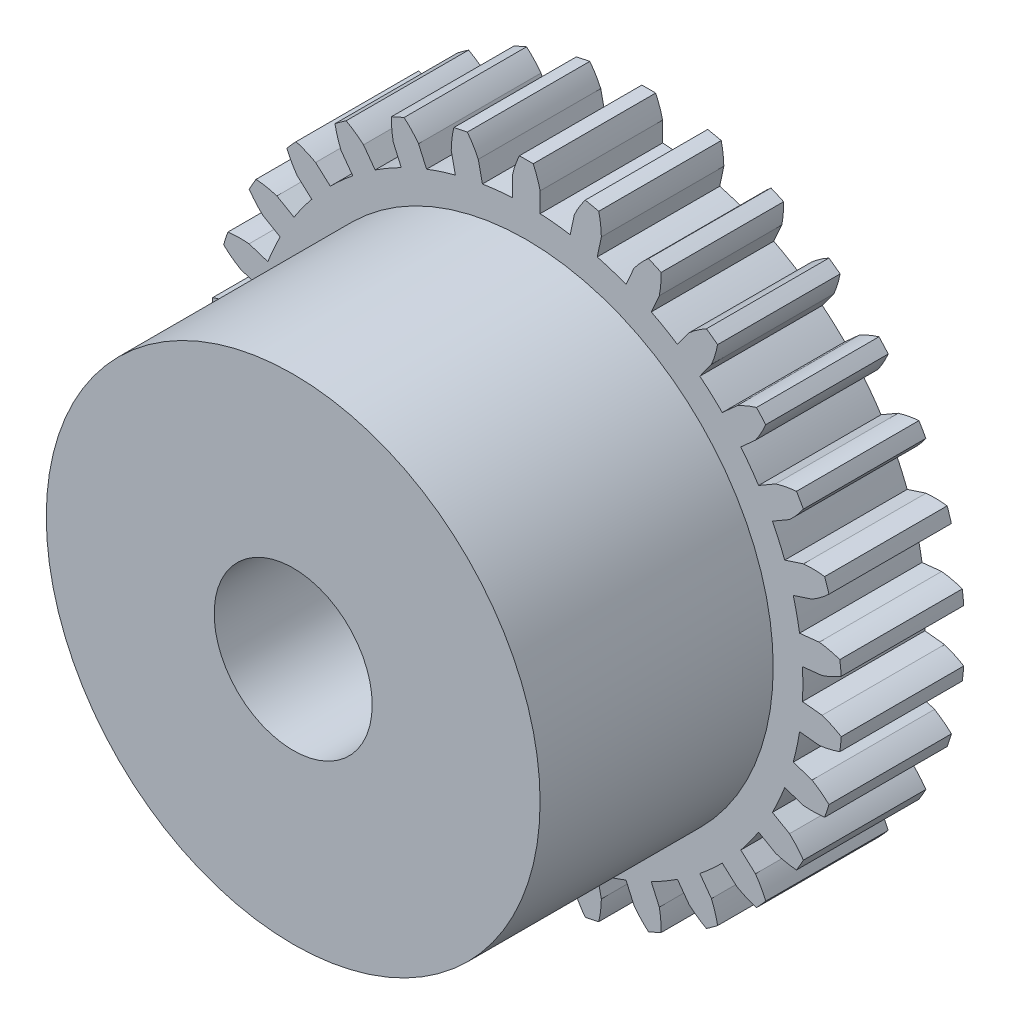
from build123d import *

# Parameters (mm, degrees)
BOSS_EXTRUDE1_DEPTH = 6.2
SKETCH2_R           = 12.5
BOSS_EXTRUDE2_DEPTH = 11.8
CUT_EXTRUDE1_REACH  = 20
SKETCH3_R           = 4
CUT_EXTRUDE2_REACH  = 18
SKETCH4_R           = 1.25


with BuildPart() as part:
    # Sketch1 → Boss-Extrude1 (new body)
    with BuildSketch(Plane.XY):
        with BuildLine():
            ThreePointArc((2.983439386, 15.719385784), (2.681848363, 15.275077472), (2.43033131, 14.8006239))
            Line((2.43033131, 14.8006239), (2.222419619, 13.822476299))
            ThreePointArc((2.222419619, 13.822476299), (1.463398486, 13.923306535), (0.7, 13.982489049))
            Line((0.7, 13.982489049), (0.7, 14.982489049))
            ThreePointArc((0.7, 14.982489049), (0.552623642, 15.498868008), (0.35, 15.996171417))
            ThreePointArc((0.35, 15.996171417), (0, 16), (-0.35, 15.996171417))
            ThreePointArc((-0.35, 15.996171417), (-0.552623642, 15.498868008), (-0.7, 14.982489049))
            Line((-0.7, 14.982489049), (-0.7, 13.982489049))
            ThreePointArc((-0.7, 13.982489049), (-1.463398486, 13.923306535), (-2.222419619, 13.822476299))
            Line((-2.222419619, 13.822476299), (-2.43033131, 14.8006239))
            ThreePointArc((-2.43033131, 14.8006239), (-2.681848363, 15.275077472), (-2.983439386, 15.719385784))
            ThreePointArc((-2.983439386, 15.719385784), (-3.326587053, 15.650361612), (-3.668142706, 15.573847601))
            ThreePointArc((-3.668142706, 15.573847601), (-3.762943343, 15.045283641), (-3.799737951, 14.509547533))
            Line((-3.799737951, 14.509547533), (-3.59182626, 13.531399932))
            ThreePointArc((-3.59182626, 13.531399932), (-4.326237921, 13.314791228), (-5.047708837, 13.058355007))
            Line((-5.047708837, 13.058355007), (-5.45444548, 13.971900465))
            ThreePointArc((-5.45444548, 13.971900465), (-5.799110727, 14.383692753), (-6.186488154, 14.755587563))
            ThreePointArc((-6.186488154, 14.755587563), (-6.507786289, 14.616727322), (-6.825969974, 14.470871913))
            ThreePointArc((-6.825969974, 14.470871913), (-6.808804364, 13.934148182), (-6.733409121, 13.402469165))
            Line((-6.733409121, 13.402469165), (-6.326672478, 12.488923707))
            ThreePointArc((-6.326672478, 12.488923707), (-7, 12.124355653), (-7.652388957, 11.723520941))
            Line((-7.652388957, 11.723520941), (-8.240174209, 12.532537935))
            ThreePointArc((-8.240174209, 12.532537935), (-8.662924124, 12.863671639), (-9.119157704, 13.14689936))
            ThreePointArc((-9.119157704, 13.14689936), (-9.404564037, 12.94427191), (-9.6854696, 12.735449683))
            ThreePointArc((-9.6854696, 12.735449683), (-9.557087961, 12.214023585), (-9.372798002, 11.709638582))
            Line((-9.372798002, 11.709638582), (-8.785012749, 10.900621588))
            ThreePointArc((-8.785012749, 10.900621588), (-9.367828489, 10.404027557), (-9.922622959, 9.876312753))
            Line((-9.922622959, 9.876312753), (-10.665767785, 10.54544336))
            ThreePointArc((-10.665767785, 10.54544336), (-11.148126168, 10.781446349), (-11.653276304, 10.963628569))
            ThreePointArc((-11.653276304, 10.963628569), (-11.890317208, 10.706089702), (-12.121667728, 10.443427191))
            ThreePointArc((-12.121667728, 10.443427191), (-11.887680954, 9.960087548), (-11.602550634, 9.505040604))
            Line((-11.602550634, 9.505040604), (-10.859405808, 8.835909998))
            ThreePointArc((-10.859405808, 8.835909998), (-11.326237921, 8.228993532), (-11.759190724, 7.597462307))
            Line((-11.759190724, 7.597462307), (-12.625216128, 8.097462307))
            ThreePointArc((-12.625216128, 8.097462307), (-13.146101604, 8.228020117), (-13.67809081, 8.3011946))
            ThreePointArc((-13.67809081, 8.3011946), (-13.856406461, 8), (-14.02809081, 7.694976817))
            ThreePointArc((-14.02809081, 7.694976817), (-13.698725246, 7.270847891), (-13.325216128, 6.885026742))
            Line((-13.325216128, 6.885026742), (-12.459190724, 6.385026742))
            ThreePointArc((-12.459190724, 6.385026742), (-12.789636407, 5.694313003), (-13.081825428, 4.986566301))
            Line((-13.081825428, 4.986566301), (-14.032881944, 5.295583296))
            ThreePointArc((-14.032881944, 5.295583296), (-14.569529318, 5.314989924), (-15.105107114, 5.275958593))
            ThreePointArc((-15.105107114, 5.275958593), (-15.216904261, 4.94427191), (-15.32141901, 4.610219032))
            ThreePointArc((-15.32141901, 4.610219032), (-14.911069512, 4.263837292), (-14.465505736, 3.964104173))
            Line((-14.465505736, 3.964104173), (-13.51444922, 3.655087178))
            ThreePointArc((-13.51444922, 3.655087178), (-13.69406641, 2.910763671), (-13.832721586, 2.15773342))
            Line((-13.832721586, 2.15773342), (-14.827243482, 2.262261883))
            ThreePointArc((-14.827243482, 2.262261883), (-15.356198688, 2.169669168), (-15.871957754, 2.02013788))
            ThreePointArc((-15.871957754, 2.02013788), (-15.912350326, 1.672455412), (-15.945127678, 1.323972553))
            ThreePointArc((-15.945127678, 1.323972553), (-15.471728488, 1.070476543), (-14.97358333, 0.869931229))
            Line((-14.97358333, 0.869931229), (-13.979061435, 0.765402766))
            ThreePointArc((-13.979061435, 0.765402766), (-14, 0), (-13.979061435, -0.765402766))
            Line((-13.979061435, -0.765402766), (-14.97358333, -0.869931229))
            ThreePointArc((-14.97358333, -0.869931229), (-15.471728488, -1.070476543), (-15.945127678, -1.323972553))
            ThreePointArc((-15.945127678, -1.323972553), (-15.912350326, -1.672455412), (-15.871957754, -2.02013788))
            ThreePointArc((-15.871957754, -2.02013788), (-15.356198688, -2.169669168), (-14.827243482, -2.262261883))
            Line((-14.827243482, -2.262261883), (-13.832721586, -2.15773342))
            ThreePointArc((-13.832721586, -2.15773342), (-13.69406641, -2.910763671), (-13.51444922, -3.655087178))
            Line((-13.51444922, -3.655087178), (-14.465505736, -3.964104173))
            ThreePointArc((-14.465505736, -3.964104173), (-14.911069512, -4.263837292), (-15.32141901, -4.610219032))
            ThreePointArc((-15.32141901, -4.610219032), (-15.216904261, -4.94427191), (-15.105107114, -5.275958593))
            ThreePointArc((-15.105107114, -5.275958593), (-14.569529318, -5.314989924), (-14.032881944, -5.295583296))
            Line((-14.032881944, -5.295583296), (-13.081825428, -4.986566301))
            ThreePointArc((-13.081825428, -4.986566301), (-12.789636407, -5.694313003), (-12.459190724, -6.385026742))
            Line((-12.459190724, -6.385026742), (-13.325216128, -6.885026742))
            ThreePointArc((-13.325216128, -6.885026742), (-13.698725246, -7.270847891), (-14.02809081, -7.694976817))
            ThreePointArc((-14.02809081, -7.694976817), (-13.856406461, -8), (-13.67809081, -8.3011946))
            ThreePointArc((-13.67809081, -8.3011946), (-13.146101604, -8.228020117), (-12.625216128, -8.097462307))
            Line((-12.625216128, -8.097462307), (-11.759190724, -7.597462307))
            ThreePointArc((-11.759190724, -7.597462307), (-11.326237921, -8.228993532), (-10.859405808, -8.835909998))
            Line((-10.859405808, -8.835909998), (-11.602550634, -9.505040604))
            ThreePointArc((-11.602550634, -9.505040604), (-11.887680954, -9.960087548), (-12.121667728, -10.443427191))
            ThreePointArc((-12.121667728, -10.443427191), (-11.890317208, -10.706089702), (-11.653276304, -10.963628569))
            ThreePointArc((-11.653276304, -10.963628569), (-11.148126168, -10.781446349), (-10.665767785, -10.54544336))
            Line((-10.665767785, -10.54544336), (-9.922622959, -9.876312753))
            ThreePointArc((-9.922622959, -9.876312753), (-9.367828489, -10.404027557), (-8.785012749, -10.900621588))
            Line((-8.785012749, -10.900621588), (-9.372798002, -11.709638582))
            ThreePointArc((-9.372798002, -11.709638582), (-9.557087961, -12.214023585), (-9.6854696, -12.735449683))
            ThreePointArc((-9.6854696, -12.735449683), (-9.404564037, -12.94427191), (-9.119157704, -13.14689936))
            ThreePointArc((-9.119157704, -13.14689936), (-8.662924124, -12.863671639), (-8.240174209, -12.532537935))
            Line((-8.240174209, -12.532537935), (-7.652388957, -11.723520941))
            ThreePointArc((-7.652388957, -11.723520941), (-7, -12.124355653), (-6.326672478, -12.488923707))
            Line((-6.326672478, -12.488923707), (-6.733409121, -13.402469165))
            ThreePointArc((-6.733409121, -13.402469165), (-6.808804364, -13.934148182), (-6.825969974, -14.470871913))
            ThreePointArc((-6.825969974, -14.470871913), (-6.507786289, -14.616727322), (-6.186488154, -14.755587563))
            ThreePointArc((-6.186488154, -14.755587563), (-5.799110727, -14.383692753), (-5.45444548, -13.971900465))
            Line((-5.45444548, -13.971900465), (-5.047708837, -13.058355007))
            ThreePointArc((-5.047708837, -13.058355007), (-4.326237921, -13.314791228), (-3.59182626, -13.531399932))
            Line((-3.59182626, -13.531399932), (-3.799737951, -14.509547533))
            ThreePointArc((-3.799737951, -14.509547533), (-3.762943343, -15.045283641), (-3.668142706, -15.573847601))
            ThreePointArc((-3.668142706, -15.573847601), (-3.326587053, -15.650361612), (-2.983439386, -15.719385784))
            ThreePointArc((-2.983439386, -15.719385784), (-2.681848363, -15.275077472), (-2.43033131, -14.8006239))
            Line((-2.43033131, -14.8006239), (-2.222419619, -13.822476299))
            ThreePointArc((-2.222419619, -13.822476299), (-1.463398486, -13.923306535), (-0.7, -13.982489049))
            Line((-0.7, -13.982489049), (-0.7, -14.982489049))
            ThreePointArc((-0.7, -14.982489049), (-0.552623642, -15.498868008), (-0.35, -15.996171417))
            ThreePointArc((-0.35, -15.996171417), (0, -16), (0.35, -15.996171417))
            ThreePointArc((0.35, -15.996171417), (0.552623642, -15.498868008), (0.7, -14.982489049))
            Line((0.7, -14.982489049), (0.7, -13.982489049))
            ThreePointArc((0.7, -13.982489049), (1.463398486, -13.923306535), (2.222419619, -13.822476299))
            Line((2.222419619, -13.822476299), (2.43033131, -14.8006239))
            ThreePointArc((2.43033131, -14.8006239), (2.681848363, -15.275077472), (2.983439386, -15.719385784))
            ThreePointArc((2.983439386, -15.719385784), (3.326587053, -15.650361612), (3.668142706, -15.573847601))
            ThreePointArc((3.668142706, -15.573847601), (3.762943343, -15.045283641), (3.799737951, -14.509547533))
            Line((3.799737951, -14.509547533), (3.59182626, -13.531399932))
            ThreePointArc((3.59182626, -13.531399932), (4.326237921, -13.314791228), (5.047708837, -13.058355007))
            Line((5.047708837, -13.058355007), (5.45444548, -13.971900465))
            ThreePointArc((5.45444548, -13.971900465), (5.799110727, -14.383692753), (6.186488154, -14.755587563))
            ThreePointArc((6.186488154, -14.755587563), (6.507786289, -14.616727322), (6.825969974, -14.470871913))
            ThreePointArc((6.825969974, -14.470871913), (6.808804364, -13.934148182), (6.733409121, -13.402469165))
            Line((6.733409121, -13.402469165), (6.326672478, -12.488923707))
            ThreePointArc((6.326672478, -12.488923707), (7, -12.124355653), (7.652388957, -11.723520941))
            Line((7.652388957, -11.723520941), (8.240174209, -12.532537935))
            ThreePointArc((8.240174209, -12.532537935), (8.662924124, -12.863671639), (9.119157704, -13.14689936))
            ThreePointArc((9.119157704, -13.14689936), (9.404564037, -12.94427191), (9.6854696, -12.735449683))
            ThreePointArc((9.6854696, -12.735449683), (9.557087961, -12.214023585), (9.372798002, -11.709638582))
            Line((9.372798002, -11.709638582), (8.785012749, -10.900621588))
            ThreePointArc((8.785012749, -10.900621588), (9.367828489, -10.404027557), (9.922622959, -9.876312753))
            Line((9.922622959, -9.876312753), (10.665767785, -10.54544336))
            ThreePointArc((10.665767785, -10.54544336), (11.148126168, -10.781446349), (11.653276304, -10.963628569))
            ThreePointArc((11.653276304, -10.963628569), (11.890317208, -10.706089702), (12.121667728, -10.443427191))
            ThreePointArc((12.121667728, -10.443427191), (11.887680954, -9.960087548), (11.602550634, -9.505040604))
            Line((11.602550634, -9.505040604), (10.859405808, -8.835909998))
            ThreePointArc((10.859405808, -8.835909998), (11.326237921, -8.228993532), (11.759190724, -7.597462307))
            Line((11.759190724, -7.597462307), (12.625216128, -8.097462307))
            ThreePointArc((12.625216128, -8.097462307), (13.146101604, -8.228020117), (13.67809081, -8.3011946))
            ThreePointArc((13.67809081, -8.3011946), (13.856406461, -8), (14.02809081, -7.694976817))
            ThreePointArc((14.02809081, -7.694976817), (13.698725246, -7.270847891), (13.325216128, -6.885026742))
            Line((13.325216128, -6.885026742), (12.459190724, -6.385026742))
            ThreePointArc((12.459190724, -6.385026742), (12.789636407, -5.694313003), (13.081825428, -4.986566301))
            Line((13.081825428, -4.986566301), (14.032881944, -5.295583296))
            ThreePointArc((14.032881944, -5.295583296), (14.569529318, -5.314989924), (15.105107114, -5.275958593))
            ThreePointArc((15.105107114, -5.275958593), (15.216904261, -4.94427191), (15.32141901, -4.610219032))
            ThreePointArc((15.32141901, -4.610219032), (14.911069512, -4.263837292), (14.465505736, -3.964104173))
            Line((14.465505736, -3.964104173), (13.51444922, -3.655087178))
            ThreePointArc((13.51444922, -3.655087178), (13.69406641, -2.910763671), (13.832721586, -2.15773342))
            Line((13.832721586, -2.15773342), (14.827243482, -2.262261883))
            ThreePointArc((14.827243482, -2.262261883), (15.356198688, -2.169669168), (15.871957754, -2.02013788))
            ThreePointArc((15.871957754, -2.02013788), (15.912350326, -1.672455412), (15.945127678, -1.323972553))
            ThreePointArc((15.945127678, -1.323972553), (15.471728488, -1.070476543), (14.97358333, -0.869931229))
            Line((14.97358333, -0.869931229), (13.979061435, -0.765402766))
            ThreePointArc((13.979061435, -0.765402766), (14, 0), (13.979061435, 0.765402766))
            Line((13.979061435, 0.765402766), (14.97358333, 0.869931229))
            ThreePointArc((14.97358333, 0.869931229), (15.471728488, 1.070476543), (15.945127678, 1.323972553))
            ThreePointArc((15.945127678, 1.323972553), (15.912350326, 1.672455412), (15.871957754, 2.02013788))
            ThreePointArc((15.871957754, 2.02013788), (15.356198688, 2.169669168), (14.827243482, 2.262261883))
            Line((14.827243482, 2.262261883), (13.832721586, 2.15773342))
            ThreePointArc((13.832721586, 2.15773342), (13.69406641, 2.910763671), (13.51444922, 3.655087178))
            Line((13.51444922, 3.655087178), (14.465505736, 3.964104173))
            ThreePointArc((14.465505736, 3.964104173), (14.911069512, 4.263837292), (15.32141901, 4.610219032))
            ThreePointArc((15.32141901, 4.610219032), (15.216904261, 4.94427191), (15.105107114, 5.275958593))
            ThreePointArc((15.105107114, 5.275958593), (14.569529318, 5.314989924), (14.032881944, 5.295583296))
            Line((14.032881944, 5.295583296), (13.081825428, 4.986566301))
            ThreePointArc((13.081825428, 4.986566301), (12.789636407, 5.694313003), (12.459190724, 6.385026742))
            Line((12.459190724, 6.385026742), (13.325216128, 6.885026742))
            ThreePointArc((13.325216128, 6.885026742), (13.698725246, 7.270847891), (14.02809081, 7.694976817))
            ThreePointArc((14.02809081, 7.694976817), (13.856406461, 8), (13.67809081, 8.3011946))
            ThreePointArc((13.67809081, 8.3011946), (13.146101604, 8.228020117), (12.625216128, 8.097462307))
            Line((12.625216128, 8.097462307), (11.759190724, 7.597462307))
            ThreePointArc((11.759190724, 7.597462307), (11.326237921, 8.228993532), (10.859405808, 8.835909998))
            Line((10.859405808, 8.835909998), (11.602550634, 9.505040604))
            ThreePointArc((11.602550634, 9.505040604), (11.887680954, 9.960087548), (12.121667728, 10.443427191))
            ThreePointArc((12.121667728, 10.443427191), (11.890317208, 10.706089702), (11.653276304, 10.963628569))
            ThreePointArc((11.653276304, 10.963628569), (11.148126168, 10.781446349), (10.665767785, 10.54544336))
            Line((10.665767785, 10.54544336), (9.922622959, 9.876312753))
            ThreePointArc((9.922622959, 9.876312753), (9.367828489, 10.404027557), (8.785012749, 10.900621588))
            Line((8.785012749, 10.900621588), (9.372798002, 11.709638582))
            ThreePointArc((9.372798002, 11.709638582), (9.557087961, 12.214023585), (9.6854696, 12.735449683))
            ThreePointArc((9.6854696, 12.735449683), (9.404564037, 12.94427191), (9.119157704, 13.14689936))
            ThreePointArc((9.119157704, 13.14689936), (8.662924124, 12.863671639), (8.240174209, 12.532537935))
            Line((8.240174209, 12.532537935), (7.652388957, 11.723520941))
            ThreePointArc((7.652388957, 11.723520941), (7, 12.124355653), (6.326672478, 12.488923707))
            Line((6.326672478, 12.488923707), (6.733409121, 13.402469165))
            ThreePointArc((6.733409121, 13.402469165), (6.808804364, 13.934148182), (6.825969974, 14.470871913))
            ThreePointArc((6.825969974, 14.470871913), (6.507786289, 14.616727322), (6.186488154, 14.755587563))
            ThreePointArc((6.186488154, 14.755587563), (5.799110727, 14.383692753), (5.45444548, 13.971900465))
            Line((5.45444548, 13.971900465), (5.047708837, 13.058355007))
            ThreePointArc((5.047708837, 13.058355007), (4.326237921, 13.314791228), (3.59182626, 13.531399932))
            Line((3.59182626, 13.531399932), (3.799737951, 14.509547533))
            ThreePointArc((3.799737951, 14.509547533), (3.762943343, 15.045283641), (3.668142706, 15.573847601))
            ThreePointArc((3.668142706, 15.573847601), (3.326587053, 15.650361612), (2.983439386, 15.719385784))
        make_face()
    extrude(amount=BOSS_EXTRUDE1_DEPTH)

    # Sketch2 → Boss-Extrude2 (add)
    with BuildSketch(Plane.XY.offset(6.2)):
        Circle(SKETCH2_R)
    extrude(amount=BOSS_EXTRUDE2_DEPTH)

    # Sketch3 → Cut-Extrude1 (cut, up to next)
    with BuildSketch(Plane.XY.offset(18), mode=Mode.PRIVATE) as cut_extrude1_sk1:
        Circle(SKETCH3_R)
    cut_extrude1_tool1 = extrude(cut_extrude1_sk1.sketch, amount=-CUT_EXTRUDE1_REACH, mode=Mode.PRIVATE) & part.part
    add(cut_extrude1_tool1.solids().sort_by_distance((0, 0, 18))[0], mode=Mode.SUBTRACT)

    # Sketch4 → Cut-Extrude2 (cut, up to next)
    with BuildSketch(Plane(origin=(0, 0, 0), x_dir=(1, 0, 0), z_dir=(0, 1, 0)), mode=Mode.PRIVATE) as cut_extrude2_sk1:
        with Locations((0, -9.7)):
            Circle(SKETCH4_R)
    cut_extrude2_tool1 = extrude(cut_extrude2_sk1.sketch, amount=-CUT_EXTRUDE2_REACH, mode=Mode.PRIVATE) & part.part
    add(cut_extrude2_tool1.solids().sort_by_distance((0, 0, 9.7))[0], mode=Mode.SUBTRACT)


solid = part.part
